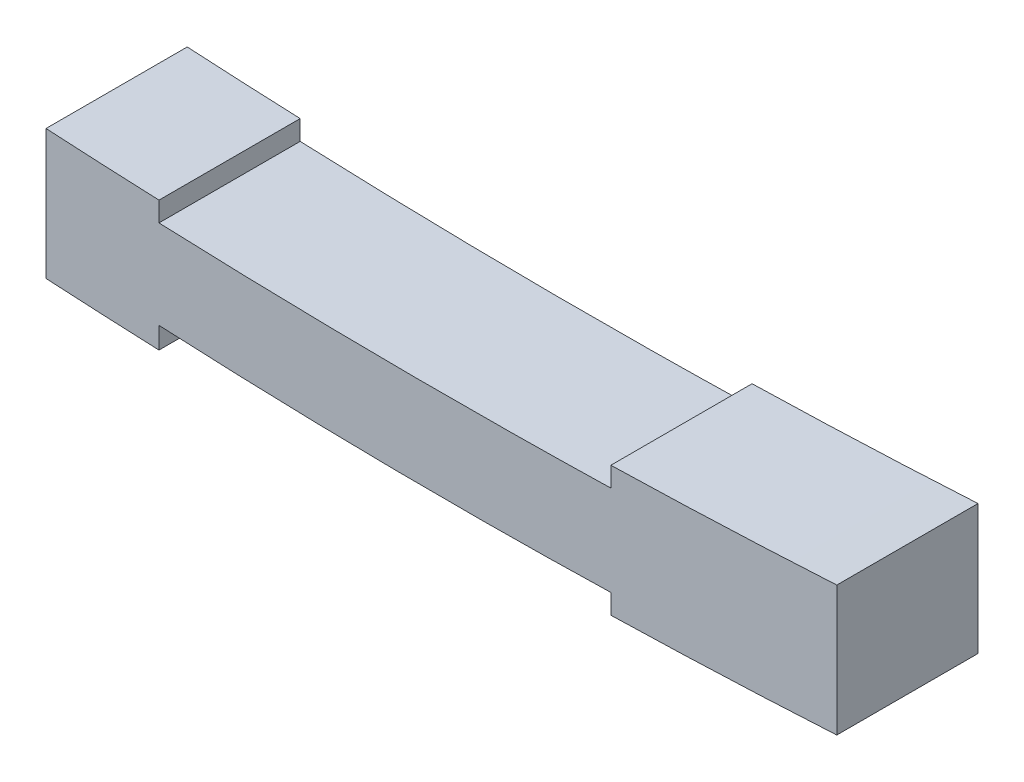
from build123d import *

# Parameters (mm, degrees)
SKETCH1_W           = 140
SKETCH1_H           = 25
BOSS_EXTRUDE1_DEPTH = 25
CUT_EXTRUDE1_DEPTH  = 25


with BuildPart() as part:
    # Sketch1 → Boss-Extrude1 (new body)
    with BuildSketch(Plane(origin=(0, 0, 0), x_dir=(1, 0, 0), z_dir=(0, 1, 0))):
        Rectangle(SKETCH1_W, SKETCH1_H)
    extrude(amount=BOSS_EXTRUDE1_DEPTH)

    # Sketch5 → Cut-Extrude1 (cut)
    with BuildSketch(Plane.XY.offset(12.5)):
        with BuildLine():
            add(Edge.make_bspline(
                [(0, 23), (15, 23), (30, 23.367346939)],
                knots=[0.5, 0.5, 0.5, 0.714285714, 0.714285714, 0.714285714], degree=2))
            add(Edge.make_bspline(
                [(30, 23.367346939), (50, 23.857142857), (70, 25)],
                knots=[0.714285714, 0.714285714, 0.714285714, 1, 1, 1], degree=2))
            Line((70, 25), (30, 25))
            Line((30, 25), (0, 25))
            Line((0, 25), (0, 23))
        make_face()
        with BuildLine():
            add(Edge.make_bspline(
                [(-50, 24.020408163), (-25, 23), (0, 23)],
                knots=[0.142857143, 0.142857143, 0.142857143, 0.5, 0.5, 0.5], degree=2))
            Line((0, 23), (0, 25))
            Line((0, 25), (-50, 25))
            Line((-50, 25), (-70, 25))
            add(Edge.make_bspline(
                [(-70, 25), (-60, 24.428571429), (-50, 24.020408163)],
                knots=[0, 0, 0, 0.142857143, 0.142857143, 0.142857143], degree=2))
        make_face()
        with BuildLine():
            Line((30, 19.867346939), (30, 23.367346939))
            add(Edge.make_bspline(
                [(0, 23), (15, 23), (30, 23.367346939)],
                knots=[0.5, 0.5, 0.5, 0.714285714, 0.714285714, 0.714285714], degree=2))
            Line((0, 23), (0, 19.5))
            add(Edge.make_bspline(
                [(0, 19.5), (14.999250637, 19.500030588), (30, 19.867346939)],
                knots=[0.625031228, 0.625031228, 0.625031228, 1, 1, 1], degree=2))
        make_face()
        with BuildLine():
            Line((0, 19.5), (0, 23))
            add(Edge.make_bspline(
                [(-50, 24.020408163), (-25, 23), (0, 23)],
                knots=[0.142857143, 0.142857143, 0.142857143, 0.5, 0.5, 0.5], degree=2))
            Line((-50, 24.020408163), (-50, 21.5))
            Line((-50, 21.5), (-50, 20.520408163))
            add(Edge.make_bspline(
                [(-50, 20.520408163), (-25.002082119, 19.499949013), (0, 19.5)],
                knots=[0, 0, 0, 0.625031228, 0.625031228, 0.625031228], degree=2))
        make_face()
        with BuildLine():
            Line((0, 0), (0, 3.5))
            add(Edge.make_bspline(
                [(-50, 4.813033374), (-25.004215516, 3.554754755), (0, 3.5)],
                knots=[0, 0, 0, 0.625063216, 0.625063216, 0.625063216], degree=2))
            Line((-50, 4.813033374), (-50, 1.020408163))
            add(Edge.make_bspline(
                [(-50, 1.020408163), (-25, 0), (0, 0)],
                knots=[0.142857143, 0.142857143, 0.142857143, 0.5, 0.5, 0.5], degree=2))
        make_face()
        with BuildLine():
            Line((30, 0.367346939), (30, 3.867346939))
            add(Edge.make_bspline(
                [(0, 3.5), (14.998483233, 3.467156007), (30, 3.867346939)],
                knots=[0.625063216, 0.625063216, 0.625063216, 1, 1, 1], degree=2))
            Line((0, 3.5), (0, 0))
            add(Edge.make_bspline(
                [(0, 0), (15, 0), (30, 0.367346939)],
                knots=[0.5, 0.5, 0.5, 0.714285714, 0.714285714, 0.714285714], degree=2))
        make_face()
        with BuildLine():
            Line((70, 0), (70, 2))
            add(Edge.make_bspline(
                [(30, 0.367346939), (50, 0.857142857), (70, 2)],
                knots=[0.714285714, 0.714285714, 0.714285714, 1, 1, 1], degree=2))
            add(Edge.make_bspline(
                [(0, 0), (15, 0), (30, 0.367346939)],
                knots=[0.5, 0.5, 0.5, 0.714285714, 0.714285714, 0.714285714], degree=2))
            Line((0, 0), (70, 0))
        make_face()
        with BuildLine():
            Line((-70, 0), (0, 0))
            add(Edge.make_bspline(
                [(-50, 1.020408163), (-25, 0), (0, 0)],
                knots=[0.142857143, 0.142857143, 0.142857143, 0.5, 0.5, 0.5], degree=2))
            add(Edge.make_bspline(
                [(-70, 2), (-60, 1.428571429), (-50, 1.020408163)],
                knots=[0, 0, 0, 0.142857143, 0.142857143, 0.142857143], degree=2))
            Line((-70, 2), (-70, 0))
        make_face()
    extrude(amount=-CUT_EXTRUDE1_DEPTH, mode=Mode.SUBTRACT)


solid = part.part
